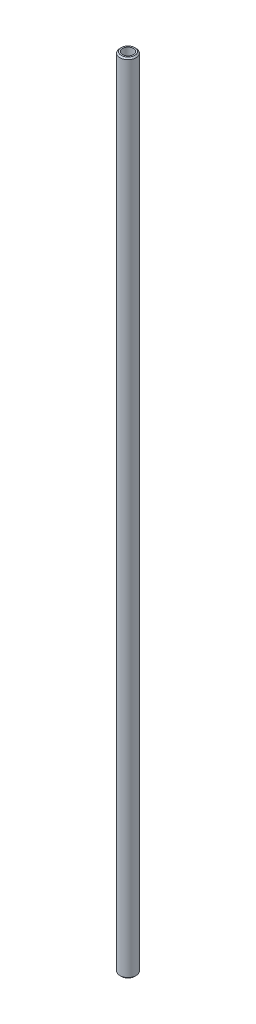
from build123d import *

# Parameters (mm, degrees)
ESQUISSE2_R        = 3
ESQUISSE2_R_2      = 2
BOSS_EXTRU_1_DEPTH = 295
CHANFREIN1_SIZE    = 0.5


with BuildPart() as part:
    # Esquisse2 → Boss.-Extru.1 (new body)
    with BuildSketch(Plane(origin=(0, 0, 0), x_dir=(1, 0, 0), z_dir=(0, 1, 0))):
        with Locations((3108.80053874, -585.321764207)):
            Circle(ESQUISSE2_R)
        with Locations((3108.80053874, -585.321764207)):
            Circle(ESQUISSE2_R_2, mode=Mode.SUBTRACT)
    extrude(amount=BOSS_EXTRU_1_DEPTH)

    # Chanfrein1
    chanfrein1_edges = [part.edges().sort_by_distance(p)[0] for p in [
        (3105.80053874, 0, 585.321764207),
        (3105.80053874, 295, 585.321764207),
    ]]
    chamfer(chanfrein1_edges, length=CHANFREIN1_SIZE)


solid = part.part
